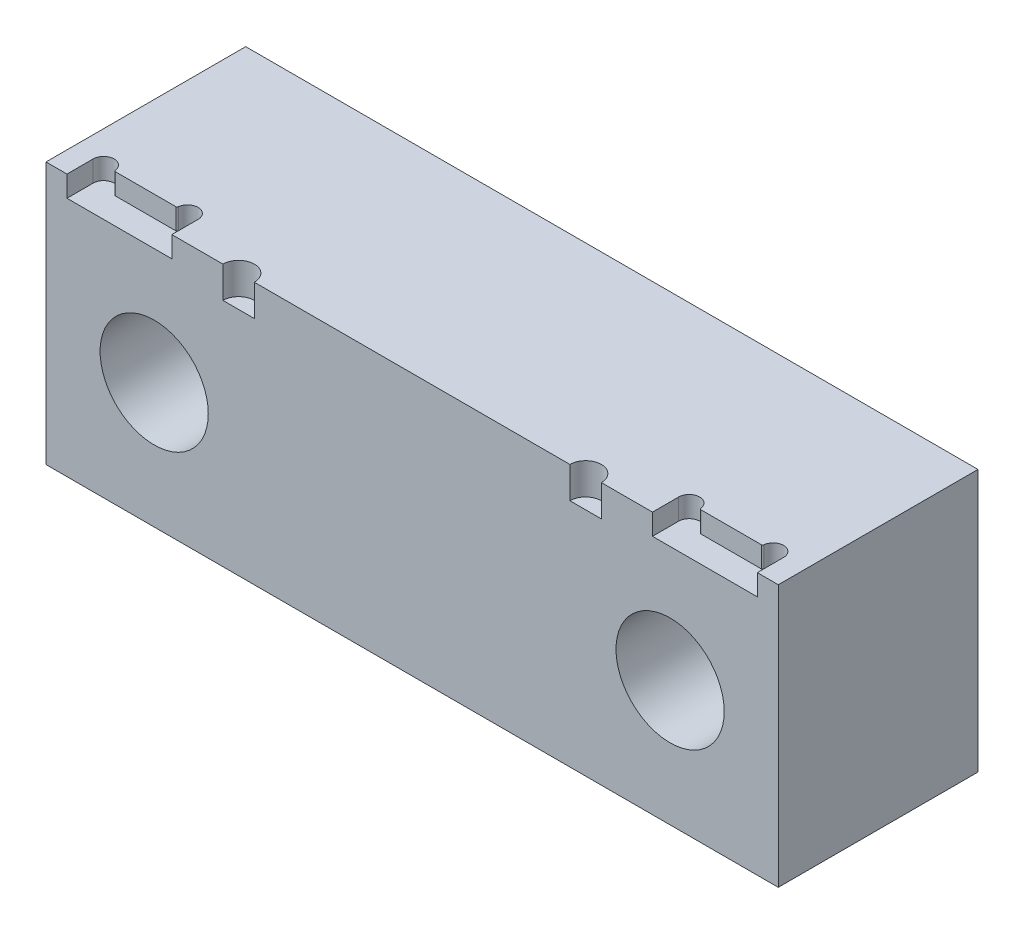
from build123d import *

# Parameters (mm, degrees)
SKETCH1_W                                        = 38.1
SKETCH1_H                                        = 50
BOSS_EXTRUDE1_DEPTH                              = 69.85
CBORE_FOR_1_2_SOCKET_HEAD_CAP_SCREW1_D           = 13.89126
CBORE_FOR_1_2_SOCKET_HEAD_CAP_SCREW1_CBORE_D     = 20.6375
CBORE_FOR_1_2_SOCKET_HEAD_CAP_SCREW1_CBORE_DEPTH = 27.94
CUT_EXTRUDE1_DEPTH                               = 6
CUT_EXTRUDE2_DEPTH                               = 4
FILLET1_R                                        = 0.254


with BuildPart() as part:
    # Sketch1 → Boss-Extrude1 (new body, symmetric)
    with BuildSketch(Plane(origin=(0, 0, 0), x_dir=(0, 0, -1), z_dir=(1, 0, 0))):
        Rectangle(SKETCH1_W, SKETCH1_H)
    extrude(amount=BOSS_EXTRUDE1_DEPTH, both=True)

    # CBORE for 1/2 Socket Head Cap Screw1 (through all)
    with Locations(Plane.XY.offset(19.05)):
        with Locations((-49.2125, -1.124), (49.2125, -1.124)):
            CounterBoreHole(CBORE_FOR_1_2_SOCKET_HEAD_CAP_SCREW1_D / 2, CBORE_FOR_1_2_SOCKET_HEAD_CAP_SCREW1_CBORE_D / 2, CBORE_FOR_1_2_SOCKET_HEAD_CAP_SCREW1_CBORE_DEPTH)

    # Sketch5 → Cut-Extrude1 (cut)
    with BuildSketch(Plane(origin=(0, 25, 0), x_dir=(1, 0, 0), z_dir=(0, 1, 0))):
        with BuildLine():
            Line((-36.1, -19.05), (-30.1, -19.05))
            ThreePointArc((-30.1, -19.05), (-33.1, -16.05), (-36.1, -19.05))
        make_face()
        with BuildLine():
            Line((36.1, -19.05), (30.1, -19.05))
            ThreePointArc((30.1, -19.05), (33.1, -16.05), (36.1, -19.05))
        make_face()
    extrude(amount=-CUT_EXTRUDE1_DEPTH, mode=Mode.SUBTRACT)

    # Sketch7 → Cut-Extrude2 (cut)
    with BuildSketch(Plane(origin=(0, 25, 0), x_dir=(1, 0, 0), z_dir=(0, 1, 0))):
        with BuildLine():
            Line((45.85, -14.05), (45.85, -19.05))
            Line((45.85, -19.05), (65.85, -19.05))
            Line((65.85, -19.05), (65.85, -14.05))
            ThreePointArc((65.85, -14.05), (63.85, -12.05), (61.85, -14.05))
            Line((61.85, -14.05), (49.85, -14.05))
            ThreePointArc((49.85, -14.05), (47.85, -12.05), (45.85, -14.05))
        make_face()
        with BuildLine():
            Line((-61.85, -14.05), (-49.85, -14.05))
            ThreePointArc((-49.85, -14.05), (-47.85, -12.05), (-45.85, -14.05))
            Line((-45.85, -14.05), (-45.85, -19.05))
            Line((-45.85, -19.05), (-65.85, -19.05))
            Line((-65.85, -19.05), (-65.85, -14.05))
            ThreePointArc((-65.85, -14.05), (-63.85, -12.05), (-61.85, -14.05))
        make_face()
    extrude(amount=-CUT_EXTRUDE2_DEPTH, mode=Mode.SUBTRACT)

    # Fillet1
    fillet1_edges = [part.edges().sort_by_distance(p)[0] for p in [
        (49.85, 23, 14.05),
        (61.85, 23, 14.05),
        (-61.85, 23, 14.05),
        (-49.85, 23, 14.05),
    ]]
    fillet(fillet1_edges, radius=FILLET1_R)


solid = part.part
